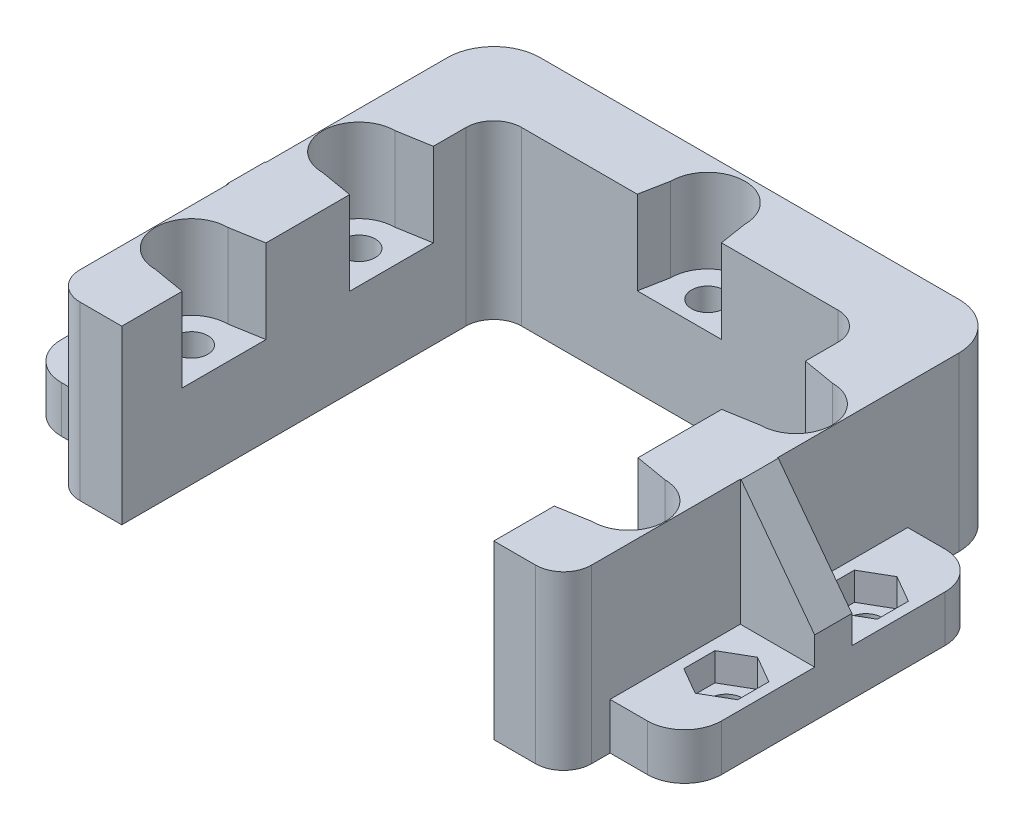
from build123d import *

# Parameters (mm, degrees)
BOSS_EXTRUDE1_DEPTH       = 18.5
SKETCH2_R                 = 1.75
CUT_EXTRUDE1_DEPTH        = 15.5
CUT_EXTRUDE2_DEPTH        = 3
SKETCH4_W                 = 32
SKETCH4_H                 = 5
BOSS_EXTRUDE2_DEPTH       = 8
FILLET1_R                 = 4
SKETCH5_R                 = 1.75
CUT_EXTRUDE3_DEPTH        = 6
SKETCH6_W                 = 4
SKETCH6_H                 = 13.5
BOSS_EXTRUDE3_DEPTH       = 8
CHAMFER1_SIZE             = 10.5
CHAMFER1_SIZE2            = 7.912317526
CUT_EXTRUDE4_DEPTH        = 3
FILLET1_OF_MIRROR1_R      = 4
CHAMFER1_OF_MIRROR1_SIZE2 = 7.912317526
CHAMFER1_OF_MIRROR1_SIZE  = 10.5
CUT_EXTRUDE7_DEPTH        = 9


with BuildPart() as part:
    # Sketch1 → Boss-Extrude1 (new body)
    with BuildSketch(Plane(origin=(0, 0, 0), x_dir=(1, 0, 0), z_dir=(0, 1, 0))):
        with BuildLine():
            Line((-20, -20), (-24.5, -20))
            ThreePointArc((-24.5, -20), (-26.621320344, -19.121320344), (-27.5, -17))
            Line((-27.5, -17), (-27.5, 22.5))
            ThreePointArc((-27.5, 22.5), (-26.035533906, 26.035533906), (-22.5, 27.5))
            Line((-22.5, 27.5), (22.5, 27.5))
            ThreePointArc((22.5, 27.5), (26.035533906, 26.035533906), (27.5, 22.5))
            Line((27.5, 22.5), (27.5, -17))
            ThreePointArc((27.5, -17), (26.621320344, -19.121320344), (24.5, -20))
            Line((24.5, -20), (20, -20))
            Line((20, -20), (20, 17))
            ThreePointArc((20, 17), (19.121320344, 19.121320344), (17, 20))
            Line((17, 20), (-17, 20))
            ThreePointArc((-17, 20), (-19.121320344, 19.121320344), (-20, 17))
            Line((-20, 17), (-20, -20))
        make_face()
    extrude(amount=BOSS_EXTRUDE1_DEPTH)

    # Sketch2 → Cut-Extrude1 (cut)
    with BuildSketch(Plane(origin=(0, 18.5, 0), x_dir=(1, 0, 0), z_dir=(0, 1, 0))):
        with Locations((-23.5, -9)):
            Circle(SKETCH2_R)
        with Locations((23.5, -9)):
            Circle(SKETCH2_R)
        with Locations((0, 23)):
            Circle(SKETCH2_R)
        with Locations((-23.5, 9)):
            Circle(SKETCH2_R)
        with Locations((23.5, 9)):
            Circle(SKETCH2_R)
    extrude(amount=-CUT_EXTRUDE1_DEPTH, mode=Mode.SUBTRACT)

    # Sketch3 → Cut-Extrude2 (cut)
    with BuildSketch(Plane.XZ):
        Polygon((-20.6, 7.325684219), (-20.6, 10.674315781), (-23.5, 12.348631561), (-26.4, 10.674315781), (-26.4, 7.325684219), (-23.5, 5.651368439), align=None)
        Polygon((23.4996681, 5.651368455), (26.399834036, 7.325396794), (26.400165936, 10.674028339), (23.5003319, 12.348631545), (20.600165964, 10.674603206), (20.599834064, 7.325971661), align=None)
        Polygon((3.348631561, -23), (1.674315781, -20.1), (-1.674315781, -20.1), (-3.348631561, -23), (-1.674315781, -25.9), (1.674315781, -25.9), align=None)
        Polygon((-23.4996681, -5.651368455), (-26.399834036, -7.325396794), (-26.400165936, -10.674028339), (-23.5003319, -12.348631545), (-20.600165964, -10.674603206), (-20.599834064, -7.325971661), align=None)
        Polygon((23.4996681, -5.651368455), (20.599834064, -7.325971661), (20.600165964, -10.674603206), (23.5003319, -12.348631545), (26.400165936, -10.674028339), (26.399834036, -7.325396794), align=None)
    extrude(amount=-CUT_EXTRUDE2_DEPTH, mode=Mode.SUBTRACT)

    # Sketch4 → Boss-Extrude2 (add)
    with BuildSketch(Plane.ZY.offset(27.5)):
        with Locations((-1, 2.5)):
            Rectangle(SKETCH4_W, SKETCH4_H)
    boss_extrude2 = extrude(amount=BOSS_EXTRUDE2_DEPTH)

    # Fillet1
    fillet1_edges = [part.edges().sort_by_distance(p)[0] for p in [
        (-35.5, 2.5, -17),
        (-35.5, 2.5, 15),
    ]]
    fillet(fillet1_edges, radius=FILLET1_R)

    # Sketch5 → Cut-Extrude3 (cut)
    with BuildSketch(Plane(origin=(0, 5, 0), x_dir=(1, 0, 0), z_dir=(0, 1, 0))):
        with Locations((-31.5, 8.5)):
            Circle(SKETCH5_R)
        with Locations((-31.5, -6.5)):
            Circle(SKETCH5_R)
    cut_extrude3 = extrude(amount=-CUT_EXTRUDE3_DEPTH, mode=Mode.SUBTRACT)

    # Sketch6 → Boss-Extrude3 (add)
    with BuildSketch(Plane.ZY.offset(27.5)):
        with Locations((-1, 11.75)):
            Rectangle(SKETCH6_W, SKETCH6_H)
    boss_extrude3 = extrude(amount=BOSS_EXTRUDE3_DEPTH)

    # Chamfer1
    chamfer1_edges = [part.edges().sort_by_distance(p)[0] for p in [
        (-35.5, 18.5, -1),
    ]]
    chamfer1_side = [part.faces().sort_by_distance(p)[0] for p in [
        (-35.5, 5.370689655, -1),
    ]]
    chamfer(chamfer1_edges, length=CHAMFER1_SIZE, length2=CHAMFER1_SIZE2, reference=chamfer1_side[0])

    # Sketch7 → Cut-Extrude4 (cut)
    with BuildSketch(Plane(origin=(0, 5, 0), x_dir=(1, 0, 0), z_dir=(0, 1, 0))):
        Polygon((-31.5, 11.848631561), (-34.4, 10.174315781), (-34.4, 6.825684219), (-31.5, 5.151368439), (-28.6, 6.825684219), (-28.6, 10.174315781), align=None)
        Polygon((-31.5, -3.151368439), (-34.4, -4.825684219), (-34.4, -8.174315781), (-31.5, -9.848631561), (-28.6, -8.174315781), (-28.6, -4.825684219), align=None)
    cut_extrude4 = extrude(amount=-CUT_EXTRUDE4_DEPTH, mode=Mode.SUBTRACT)

    # Mirror1: Boss-Extrude2, Cut-Extrude3, Boss-Extrude3, Cut-Extrude4 across plane
    add(boss_extrude2.mirror(Plane(origin=(0, 0, 0), x_dir=(0, 0, 1), z_dir=(1, 0, 0))))
    add(cut_extrude3.mirror(Plane(origin=(0, 0, 0), x_dir=(0, 0, 1), z_dir=(1, 0, 0))), mode=Mode.SUBTRACT)
    add(boss_extrude3.mirror(Plane(origin=(0, 0, 0), x_dir=(0, 0, 1), z_dir=(1, 0, 0))))
    add(cut_extrude4.mirror(Plane(origin=(0, 0, 0), x_dir=(0, 0, 1), z_dir=(1, 0, 0))), mode=Mode.SUBTRACT)

    # Fillet1 of Mirror1
    fillet1_of_mirror1_edges = [part.edges().sort_by_distance(p)[0] for p in [
        (35.5, 2.5, -17),
        (35.5, 2.5, 15),
    ]]
    fillet(fillet1_of_mirror1_edges, radius=FILLET1_OF_MIRROR1_R)

    # Chamfer1 of Mirror1
    chamfer1_of_mirror1_edges = [part.edges().sort_by_distance(p)[0] for p in [
        (35.5, 18.5, -1),
    ]]
    chamfer(chamfer1_of_mirror1_edges, length=CHAMFER1_OF_MIRROR1_SIZE, length2=CHAMFER1_OF_MIRROR1_SIZE2)

    # Sketch8 → Cut-Extrude7 (cut)
    with BuildSketch(Plane(origin=(0, 18.5, 0), x_dir=(1, 0, 0), z_dir=(0, 1, 0))):
        with BuildLine():
            Line((-4, 23), (-4.57455059, 20))
            Line((-4.57455059, 20), (4.478329848, 20))
            Line((4.478329848, 20), (4, 23))
            ThreePointArc((4, 23), (0, 27), (-4, 23))
        make_face()
        with BuildLine():
            Line((23.5, 12.9), (20, 13.5))
            Line((20, 13.5), (20, 4.5))
            Line((20, 4.5), (23.5, 5.1))
            ThreePointArc((23.5, 5.1), (27.4, 9), (23.5, 12.9))
        make_face()
        with BuildLine():
            Line((23.5, -5.1), (20, -4.5))
            Line((20, -4.5), (20, -13.5))
            Line((20, -13.5), (23.5, -12.9))
            ThreePointArc((23.5, -12.9), (27.4, -9), (23.5, -5.1))
        make_face()
        with BuildLine():
            Line((-23.5, -12.9), (-20, -13.5))
            Line((-20, -13.5), (-20, -4.5))
            Line((-20, -4.5), (-23.5, -5.1))
            ThreePointArc((-23.5, -5.1), (-27.4, -9), (-23.5, -12.9))
        make_face()
        with BuildLine():
            Line((-23.5, 12.9), (-20, 13.5))
            Line((-20, 13.5), (-20, 4.5))
            Line((-20, 4.5), (-23.5, 5.1))
            ThreePointArc((-23.5, 5.1), (-27.4, 9), (-23.5, 12.9))
        make_face()
    extrude(amount=-CUT_EXTRUDE7_DEPTH, mode=Mode.SUBTRACT)


solid = part.part
